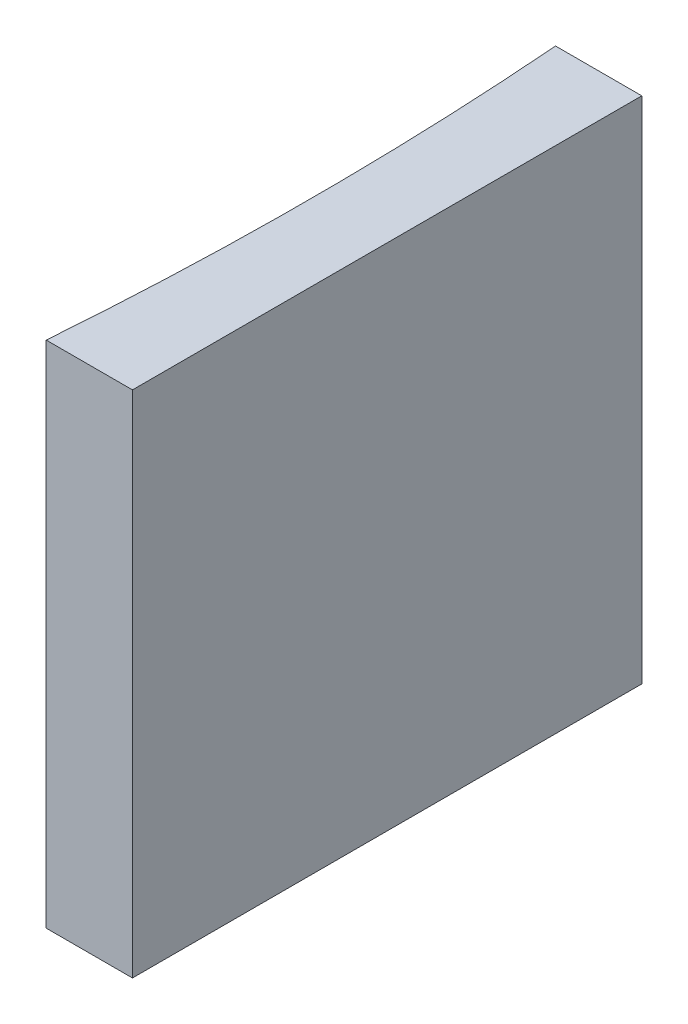
from build123d import *

# Parameters (mm, degrees)
EXTRUDE_1_DEPTH = 20


with BuildPart() as part:
    # 草图1 → 凸台-拉伸1 (new body)
    with BuildSketch(Plane(origin=(0, 0, 0), x_dir=(1, 0, 0), z_dir=(0, 1, 0))):
        with BuildLine():
            Line((0, 0), (0, -20))
            Line((0, -20), (-3.387427854, -20))
            ThreePointArc((-3.387427854, -20), (-3, -10), (-3.387427854, 0))
            Line((-3.387427854, 0), (0, 0))
        make_face()
    extrude(amount=EXTRUDE_1_DEPTH)


solid = part.part
